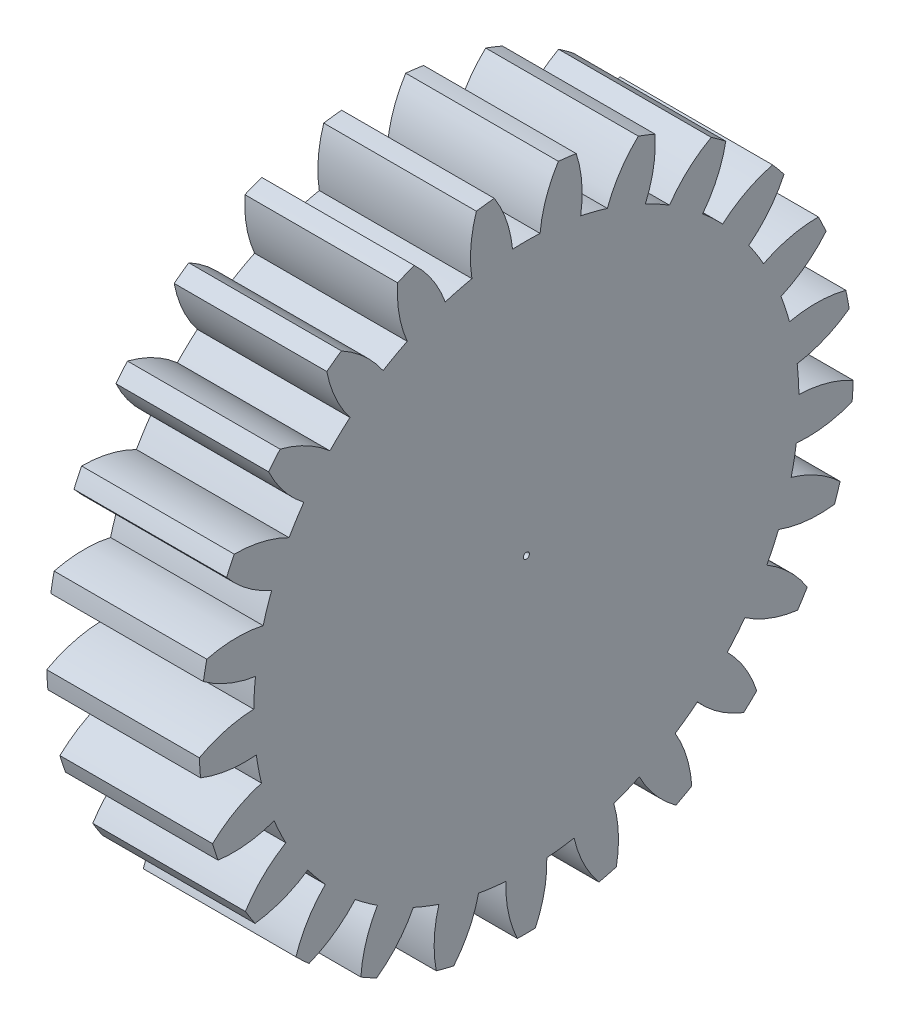
from build123d import *

# Parameters (mm, degrees)
BASPROSKE_W     = 20.000000005
BASPROSKE_H     = 42.8625
TOOTHCUT_DEPTH  = 64.830931473
TEETHCUTS_COUNT = 25
TEETHCUTS_ANGLE = 345.6
BORSKE_R        = 0.396875
BORE_DEPTH      = 50.8000508


with BuildPart() as part:
    # BasProSke → Base-Revolve (revolve)
    with BuildSketch(Plane(origin=(0, 0, 0), x_dir=(1, 0, 0), z_dir=(0, 1, 0)), mode=Mode.PRIVATE) as base_revolve_sk:
        with Locations((10.000000003, 21.43125)):
            Rectangle(BASPROSKE_W, BASPROSKE_H)
    revolve(base_revolve_sk.sketch.rotate(Axis((-10, 0, 0), (1, 0, 0)), 180), axis=Axis((-10, 0, 0), (1, 0, 0)))

    # TooCutSke → ToothCut (cut, through all)
    with BuildSketch(Plane(origin=(0, 0, 0), x_dir=(0, 0, -1), z_dir=(1, 0, 0))):
        with BuildLine():
            ThreePointArc((1.802497989, 35.671969087), (0, 35.71748), (-1.802497989, 35.671969087))
            ThreePointArc((-1.802497989, 35.671969087), (-2.593678058, 39.318881462), (-4.21433861, 42.680338758))
            ThreePointArc((-4.21433861, 42.680338758), (0, 42.8879), (4.21433861, 42.680338758))
            ThreePointArc((4.21433861, 42.680338758), (2.593678058, 39.318881462), (1.802497989, 35.671969087))
        make_face()
    toothcut = extrude(amount=TOOTHCUT_DEPTH, mode=Mode.SUBTRACT)

    # TeethCuts: ToothCut ×25 about axis
    teethcuts_axis = Axis((-10, 0, 0), (1, 0, 0))
    for i in range(1, TEETHCUTS_COUNT):
        add(toothcut.rotate(teethcuts_axis, i * TEETHCUTS_ANGLE / (TEETHCUTS_COUNT - 1)), mode=Mode.SUBTRACT)

    # BorSke → Bore (cut, symmetric)
    with BuildSketch(Plane(origin=(0, 0, 0), x_dir=(0, 0, -1), z_dir=(1, 0, 0))):
        with Locations(Location((0, 0, 0), (0, 0, 180))):
            Circle(BORSKE_R)
    extrude(amount=BORE_DEPTH, both=True, mode=Mode.SUBTRACT)


solid = part.part
